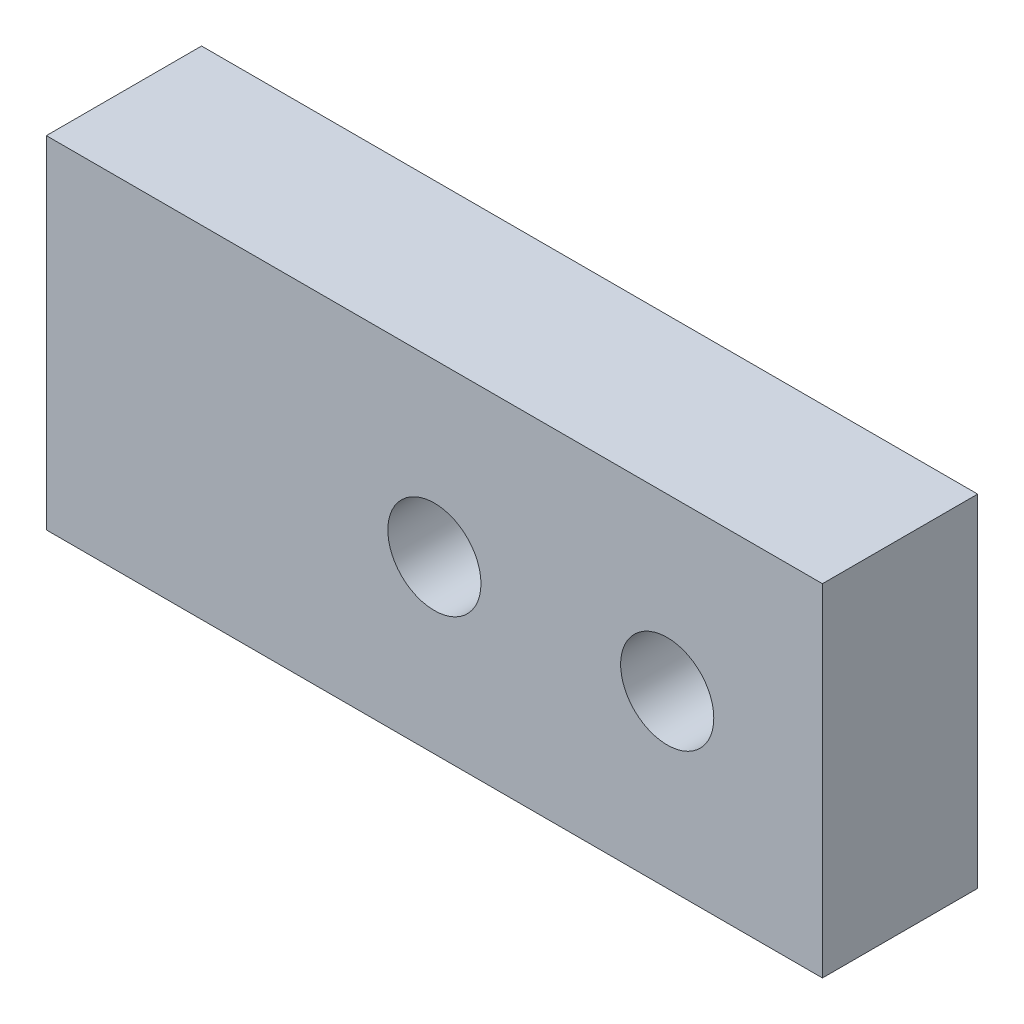
from build123d import *

# Parameters (mm, degrees)
SKETCH1_W             = 50
SKETCH1_H             = 22
BOSS_EXTRUDE1_DEPTH   = 10
M5_TAPPED_HOLE1_D     = 4.2
M5_TAPPED_HOLE1_DEPTH = 14
M5_TAPPED_HOLE1_TIP   = 1.2618073
SKETCH5_R             = 3
CUT_EXTRUDE1_DEPTH    = 10


with BuildPart() as part:
    # Sketch1 → Boss-Extrude1 (new body)
    with BuildSketch(Plane.XY):
        Rectangle(SKETCH1_W, SKETCH1_H)
    extrude(amount=BOSS_EXTRUDE1_DEPTH)

    # M5 Tapped Hole1
    with Locations(Plane.ZY.offset(25)):
        with Locations((5, -6), (5, 6)):
            Hole(M5_TAPPED_HOLE1_D / 2, depth=M5_TAPPED_HOLE1_DEPTH)
            with Locations((0, 0, -(M5_TAPPED_HOLE1_DEPTH + M5_TAPPED_HOLE1_TIP / 2))):  # 118° drill point
                Cone(0, M5_TAPPED_HOLE1_D / 2, M5_TAPPED_HOLE1_TIP, mode=Mode.SUBTRACT)

    # Sketch5 → Cut-Extrude1 (cut)
    with BuildSketch(Plane.XY.offset(10)):
        with Locations((15, 0)):
            Circle(SKETCH5_R)
        Circle(SKETCH5_R)
    extrude(amount=-CUT_EXTRUDE1_DEPTH, mode=Mode.SUBTRACT)


solid = part.part
